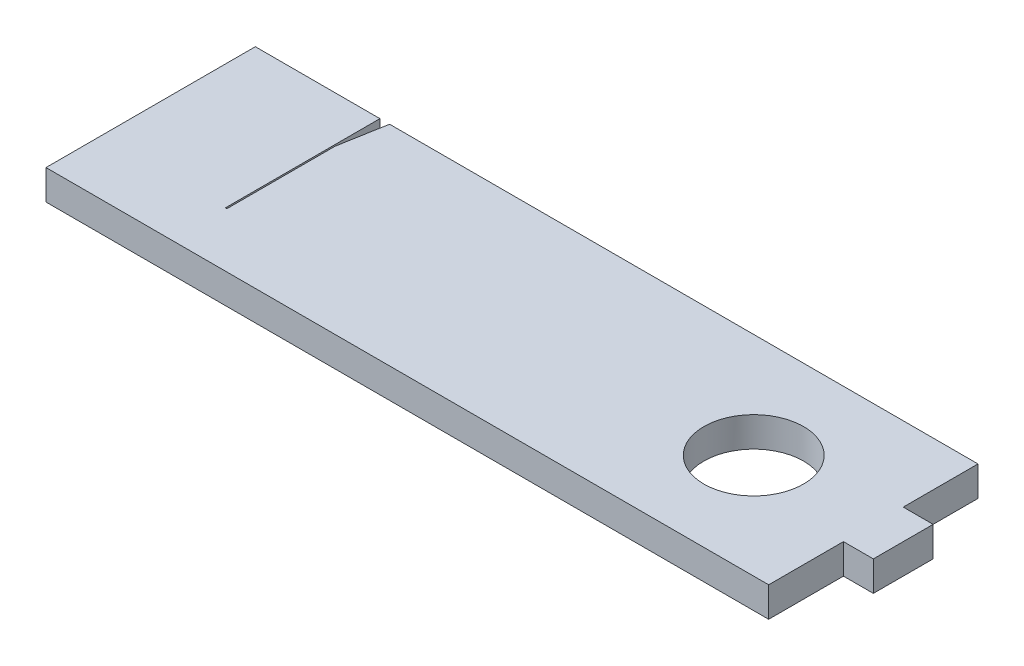
from build123d import *

# Parameters (mm, degrees)
SKETCH1_W           = 145
SKETCH1_H           = 42
BOSS_EXTRUDE1_DEPTH = 6
SKETCH3_R           = 4
CUT_EXTRUDE1_DEPTH  = 7
SKETCH4_W           = 6
SKETCH4_H           = 12
BOSS_EXTRUDE2_DEPTH = 6
BOSS_EXTRUDE3_DEPTH = 6
SKETCH7_R           = 0.75
CUT_EXTRUDE2_DEPTH  = 7
CUT_EXTRUDE3_DEPTH  = 7
SKETCH9_R           = 10
CUT_EXTRUDE4_DEPTH  = 10


with BuildPart() as part:
    # Sketch1 → Boss-Extrude1 (new body)
    with BuildSketch(Plane(origin=(0, 0, 0), x_dir=(1, 0, 0), z_dir=(0, 1, 0))):
        Rectangle(SKETCH1_W, SKETCH1_H)
    extrude(amount=BOSS_EXTRUDE1_DEPTH)

    # Sketch3 → Cut-Extrude1 (cut, through all)
    with BuildSketch(Plane.XZ):
        with Locations((48.5, 0)):
            Circle(SKETCH3_R)
    extrude(amount=-CUT_EXTRUDE1_DEPTH, mode=Mode.SUBTRACT)

    # Sketch4 → Boss-Extrude2 (add)
    with BuildSketch(Plane(origin=(0, 6, 0), x_dir=(1, 0, 0), z_dir=(0, 1, 0))):
        with Locations((75.5, 0)):
            Rectangle(SKETCH4_W, SKETCH4_H)
    extrude(amount=-BOSS_EXTRUDE2_DEPTH)

    # Sketch5 → Boss-Extrude3 (add)
    with BuildSketch(Plane(origin=(0, 6, 0), x_dir=(1, 0, 0), z_dir=(0, 1, 0))):
        Polygon((-59.5, -10), (-72.5, -10), (-72.5, -21), (-53.5, -21), (-53.5, -17.5), (-59.5, -17.5), align=None)
    extrude(amount=-BOSS_EXTRUDE3_DEPTH)

    # Sketch7 → Cut-Extrude2 (cut, through all)
    with BuildSketch(Plane.XZ):
        with Locations((-161.479103552, -154.351327649)):
            Circle(SKETCH7_R)
    extrude(amount=-CUT_EXTRUDE2_DEPTH, mode=Mode.SUBTRACT)

    # Sketch8 → Cut-Extrude3 (cut, through all)
    with BuildSketch(Plane(origin=(0, 6, 0), x_dir=(1, 0, 0), z_dir=(0, 1, 0))):
        Polygon((-47.5, 21), (-47.5, -10), (-47.2, -10), (-47.2, 11.701384546), (-45.560403212, 21), align=None)
    extrude(amount=-CUT_EXTRUDE3_DEPTH, mode=Mode.SUBTRACT)

    # Sketch9 → Cut-Extrude4 (cut)
    with BuildSketch(Plane(origin=(0, 6, 0), x_dir=(1, 0, 0), z_dir=(0, 1, 0))):
        with Locations((48.5, 0)):
            Circle(SKETCH9_R)
    extrude(amount=-CUT_EXTRUDE4_DEPTH, mode=Mode.SUBTRACT)


solid = part.part
